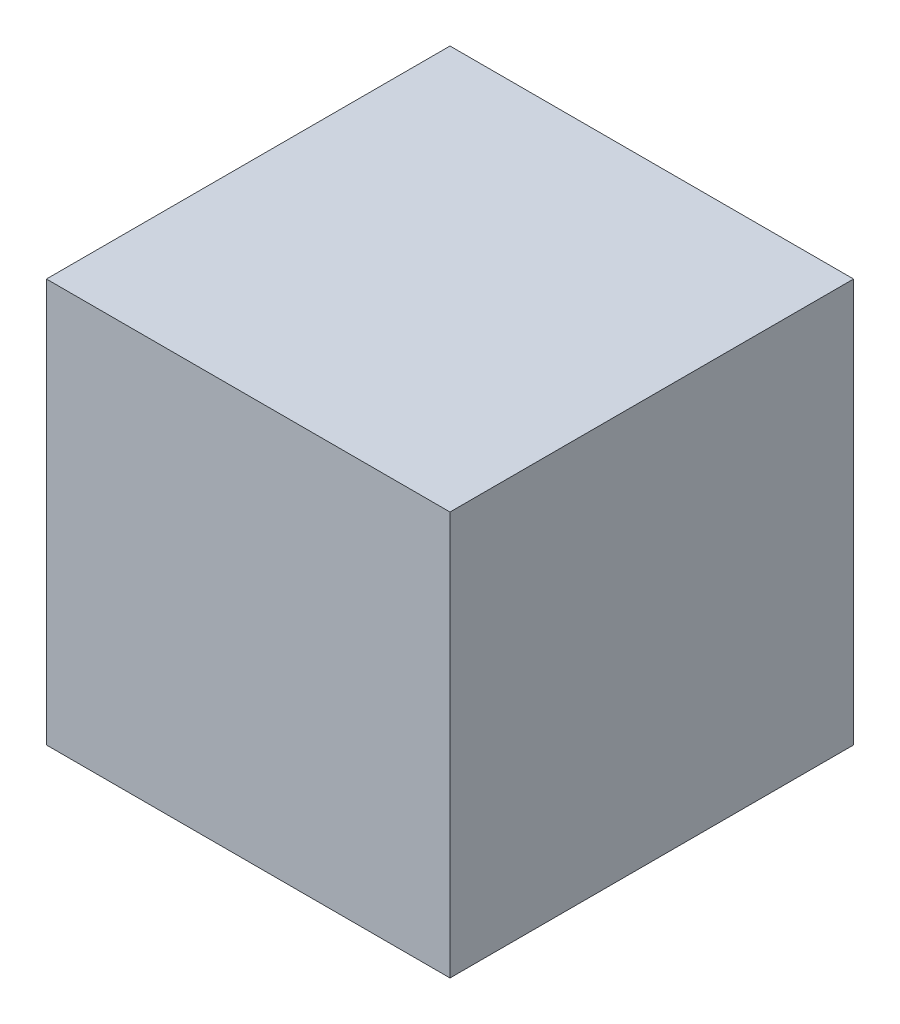
from build123d import *

# Parameters (mm, degrees)
SKETCH1_W           = 23
SKETCH1_H           = 23
BOSS_EXTRUDE1_DEPTH = 23


with BuildPart() as part:
    # Sketch1 → Boss-Extrude1 (new body)
    with BuildSketch(Plane.XY):
        with Locations((-11.5, 11.5)):
            Rectangle(SKETCH1_W, SKETCH1_H)
    extrude(amount=BOSS_EXTRUDE1_DEPTH)


solid = part.part
